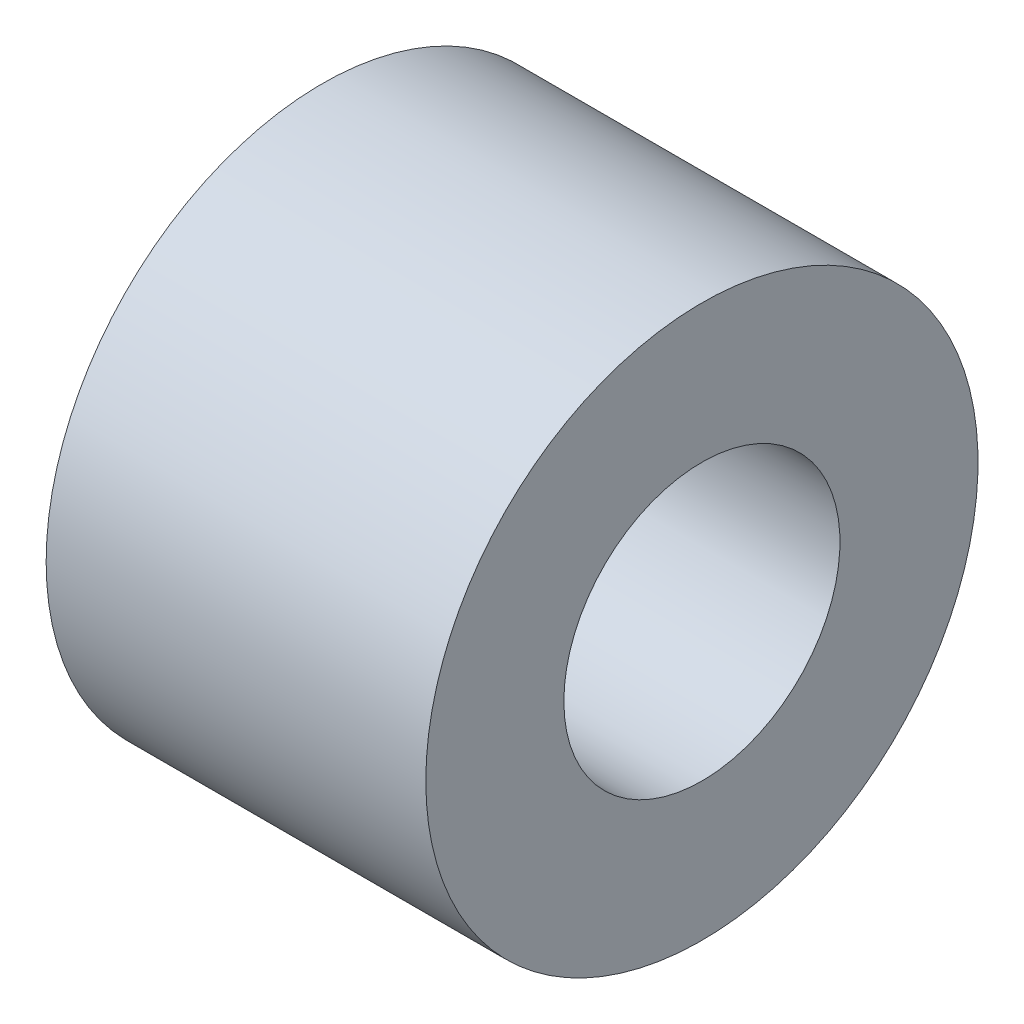
from build123d import *

# Parameters (mm, degrees)
SKETCH1_W = 5.5
SKETCH1_H = 2


with BuildPart() as part:
    # Sketch1 → Revolve1 (revolve)
    with BuildSketch(Plane.XY):
        with Locations((2.75, -3)):
            Rectangle(SKETCH1_W, SKETCH1_H)
    revolve(axis=Axis((0, 0, 0), (1, 0, 0)))


solid = part.part
